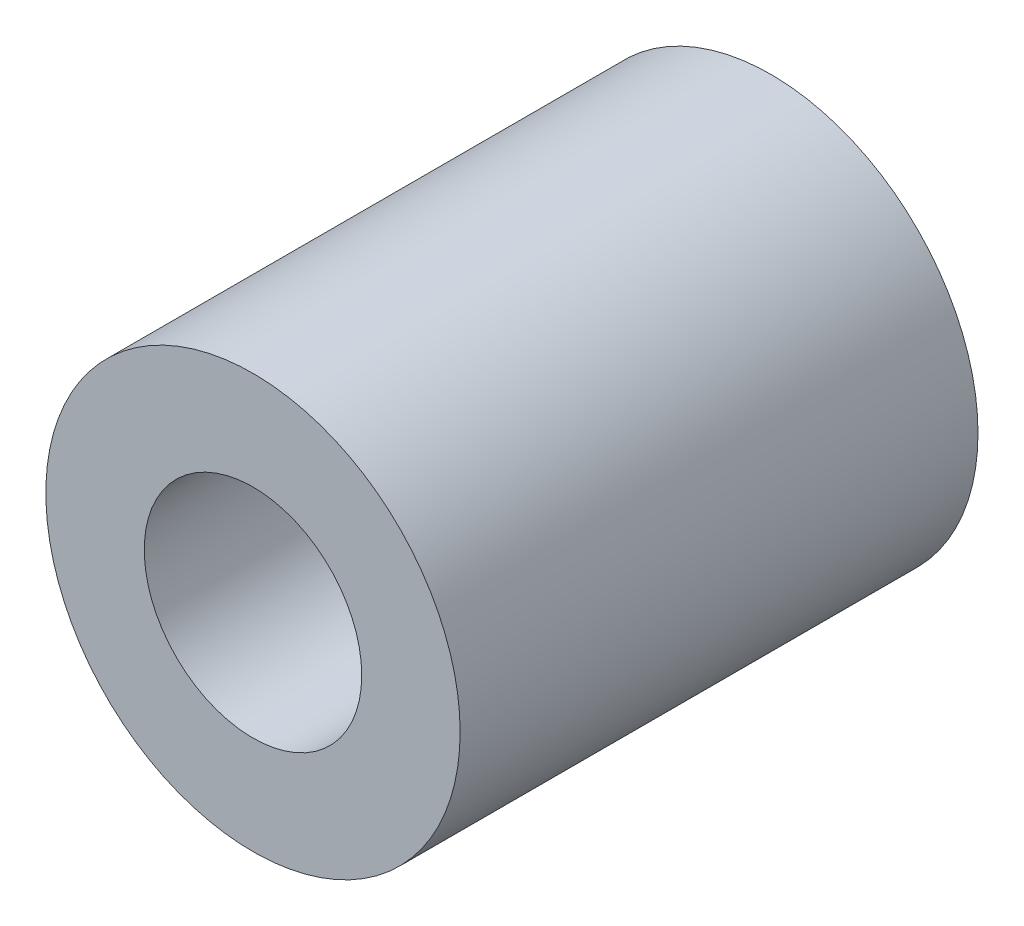
from build123d import *

# Parameters (mm, degrees)
SKETCH_1_R      = 4
SKETCH_1_R_2    = 2.1
EXTRUDE_1_DEPTH = 5


with BuildPart() as part:
    # 草图1 → 凸台-拉伸1 (new body, symmetric)
    with BuildSketch(Plane.XY):
        Circle(SKETCH_1_R)
        Circle(SKETCH_1_R_2, mode=Mode.SUBTRACT)
    extrude(amount=EXTRUDE_1_DEPTH, both=True)


solid = part.part
